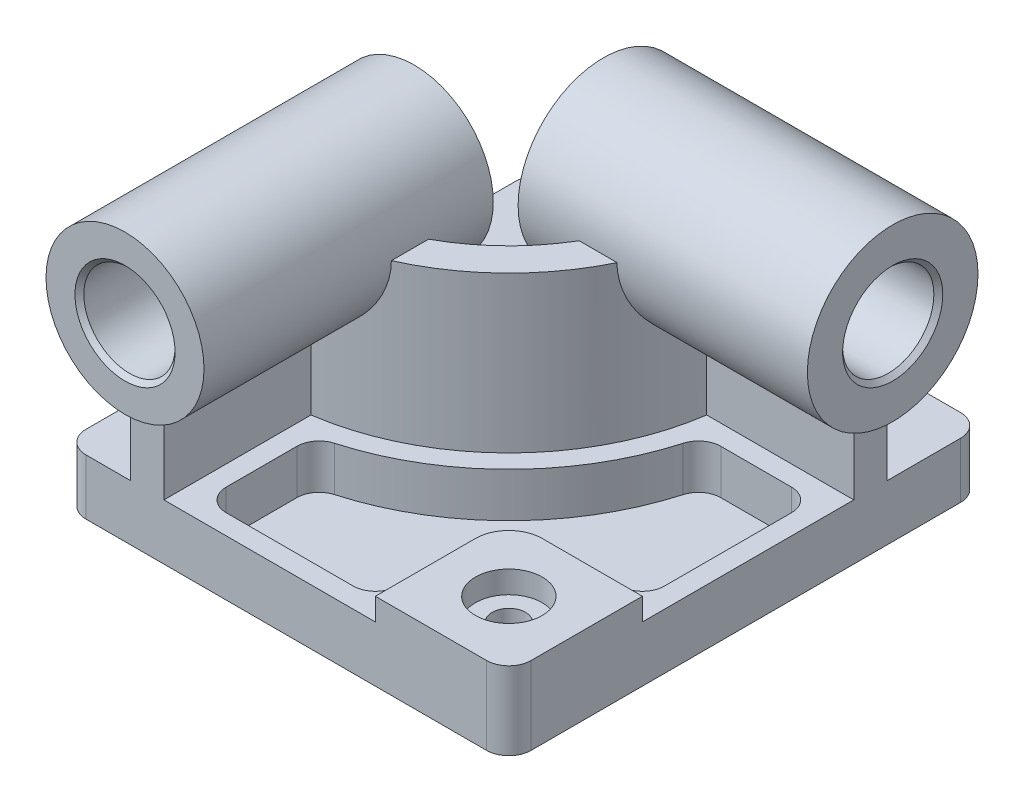
from build123d import *

# Parameters (mm, degrees)
EXTRUDE_1_DEPTH              = 25
EXTRUDE_2_DEPTH              = 10
HOLE_WIZARD_M8_1_D           = 15
HOLE_WIZARD_M8_1_CBORE_D     = 30
HOLE_WIZARD_M8_1_CBORE_DEPTH = 10
CUT_EXTRUDE_1_DEPTH          = 20
SKETCH_6_R                   = 35.5
EXTRUDE_3_DEPTH              = 130
SKETCH_7_R                   = 38.335
EXTRUDE_4_DEPTH              = 130
EXTRUDE_8_DEPTH              = 70
CUT_EXTRUDE_2_REACH          = 225
SKETCH_9_R                   = 20.5
CUT_EXTRUDE_3_REACH          = 212
SKETCH_10_R                  = 20.5
CHAMFER_1_SIZE               = 2


with BuildPart() as part:
    # 스케치1 → 보스-돌출1 (new body)
    with BuildSketch(Plane(origin=(0, 0, 0), x_dir=(1, 0, 0), z_dir=(0, 1, 0))):
        with BuildLine():
            Line((10, 0), (190, 0))
            ThreePointArc((190, 0), (197.071067812, 2.928932188), (200, 10))
            Line((200, 10), (200, 203))
            ThreePointArc((200, 203), (197.071067812, 210.071067812), (190, 213))
            Line((190, 213), (10, 213))
            ThreePointArc((10, 213), (2.928932188, 210.071067812), (0, 203))
            Line((0, 203), (0, 10))
            ThreePointArc((0, 10), (2.928932188, 2.928932188), (10, 0))
        make_face()
    extrude(amount=EXTRUDE_1_DEPTH)

    # 스케치2 → 보스-돌출2 (add)
    with BuildSketch(Plane(origin=(0, 25, 0), x_dir=(1, 0, 0), z_dir=(0, 1, 0))):
        with BuildLine():
            Line((140, 0), (190, 0))
            ThreePointArc((190, 0), (197.071067812, 2.928932188), (200, 10))
            Line((200, 10), (200, 60))
            Line((200, 60), (155, 60))
            ThreePointArc((155, 60), (144.393398282, 55.606601718), (140, 45))
            Line((140, 45), (140, 0))
        make_face()
    extrude(amount=EXTRUDE_2_DEPTH)

    # M8 육각 머리 볼트용 카운터보어1 (through all)
    with Locations(Plane(origin=(170, 35, -30), x_dir=(0, 0, 1), z_dir=(0, 1, 0))):
        with Locations((0, 0)):
            CounterBoreHole(HOLE_WIZARD_M8_1_D / 2, HOLE_WIZARD_M8_1_CBORE_D / 2, HOLE_WIZARD_M8_1_CBORE_DEPTH)

    # 스케치5 → 컷-돌출1 (cut)
    with BuildSketch(Plane(origin=(0, 25, 0), x_dir=(1, 0, 0), z_dir=(0, 1, 0))):
        with BuildLine():
            Line((149.247641486, 146), (181, 146))
            ThreePointArc((181, 146), (188.071067812, 143.071067812), (191, 136))
            Line((191, 136), (191, 79))
            ThreePointArc((191, 79), (188.071067812, 71.928932188), (181, 69))
            Line((181, 69), (155, 69))
            ThreePointArc((155, 69), (138.029437252, 61.970562748), (131, 45))
            Line((131, 45), (131, 19))
            ThreePointArc((131, 19), (128.071067812, 11.928932188), (121, 9))
            Line((121, 9), (64, 9))
            ThreePointArc((64, 9), (56.928932188, 11.928932188), (54, 19))
            Line((54, 19), (54, 50.752358514))
            ThreePointArc((54, 50.752358514), (56.018165786, 56.776503481), (61.258064516, 60.369103795))
            ThreePointArc((61.258064516, 60.369103795), (110.610173055, 89.389826945), (139.630896205, 138.741935484))
            ThreePointArc((139.630896205, 138.741935484), (143.223496519, 143.981834214), (149.247641486, 146))
        make_face()
    extrude(amount=-CUT_EXTRUDE_1_DEPTH, mode=Mode.SUBTRACT)



with BuildPart() as body_2:
    # 스케치6 → 보스-돌출3 (new body)
    with BuildSketch(Plane.XY.offset(10)):
        with Locations((37.5, 95)):
            Circle(SKETCH_6_R)
    extrude(amount=-EXTRUDE_3_DEPTH)


with BuildPart() as body_3:
    # 스케치7 → 보스-돌출4 (new body)
    with BuildSketch(Plane(origin=(210, 0, 0), x_dir=(0, 0, -1), z_dir=(1, 0, 0))):
        with Locations((162.5, 95)):
            Circle(SKETCH_7_R)
    extrude(amount=-EXTRUDE_4_DEPTH)


with BuildPart() as part_1:
    add(part.part)

    add(body_2.part)  # 보스-돌출8 merges body 2

    add(body_3.part)  # 보스-돌출8 merges body 3
    # 스케치8 → 보스-돌출8 (add)
    with BuildSketch(Plane(origin=(0, 25, 0), x_dir=(1, 0, 0), z_dir=(0, 1, 0))):
        with BuildLine():
            Line((30, 0), (45, 0))
            Line((45, 0), (45, 66.076951546))
            ThreePointArc((45, 66.076951546), (104.246212025, 95.753787975), (133.923048454, 155))
            Line((133.923048454, 155), (200, 155))
            Line((200, 155), (200, 170))
            Line((200, 170), (120, 170))
            ThreePointArc((120, 170), (93.639610307, 106.360389693), (30, 80))
            Line((30, 80), (30, 0))
        make_face()
    extrude(amount=EXTRUDE_8_DEPTH)

    # 스케치9 → 컷-돌출2 (cut, up to next)
    with BuildSketch(Plane.XY.offset(10), mode=Mode.PRIVATE) as cut_extrude_2_sk1:
        with Locations((37.5, 95)):
            Circle(SKETCH_9_R)
    cut_extrude_2_tool1 = extrude(cut_extrude_2_sk1.sketch, amount=-CUT_EXTRUDE_2_REACH, mode=Mode.PRIVATE) & part_1.part
    add(cut_extrude_2_tool1.solids().sort_by_distance((37.5, 95, 10))[0], mode=Mode.SUBTRACT)

    # 스케치10 → 컷-돌출3 (cut, up to next)
    with BuildSketch(Plane(origin=(210, 0, 0), x_dir=(0, 0, -1), z_dir=(1, 0, 0)), mode=Mode.PRIVATE) as cut_extrude_3_sk1:
        with Locations((162.5, 95)):
            Circle(SKETCH_10_R)
    cut_extrude_3_tool1 = extrude(cut_extrude_3_sk1.sketch, amount=-CUT_EXTRUDE_3_REACH, mode=Mode.PRIVATE) & part_1.part
    add(cut_extrude_3_tool1.solids().sort_by_distance((210, 95, -162.5))[0], mode=Mode.SUBTRACT)

    # 모따기1
    chamfer_1_edges = [part_1.edges().sort_by_distance(p)[0] for p in [
        (17, 95, 10),
        (17, 95, -120),
        (210, 95, -142),
        (80, 95, -142),
    ]]
    chamfer(chamfer_1_edges, length=CHAMFER_1_SIZE)


solid = part_1.part
